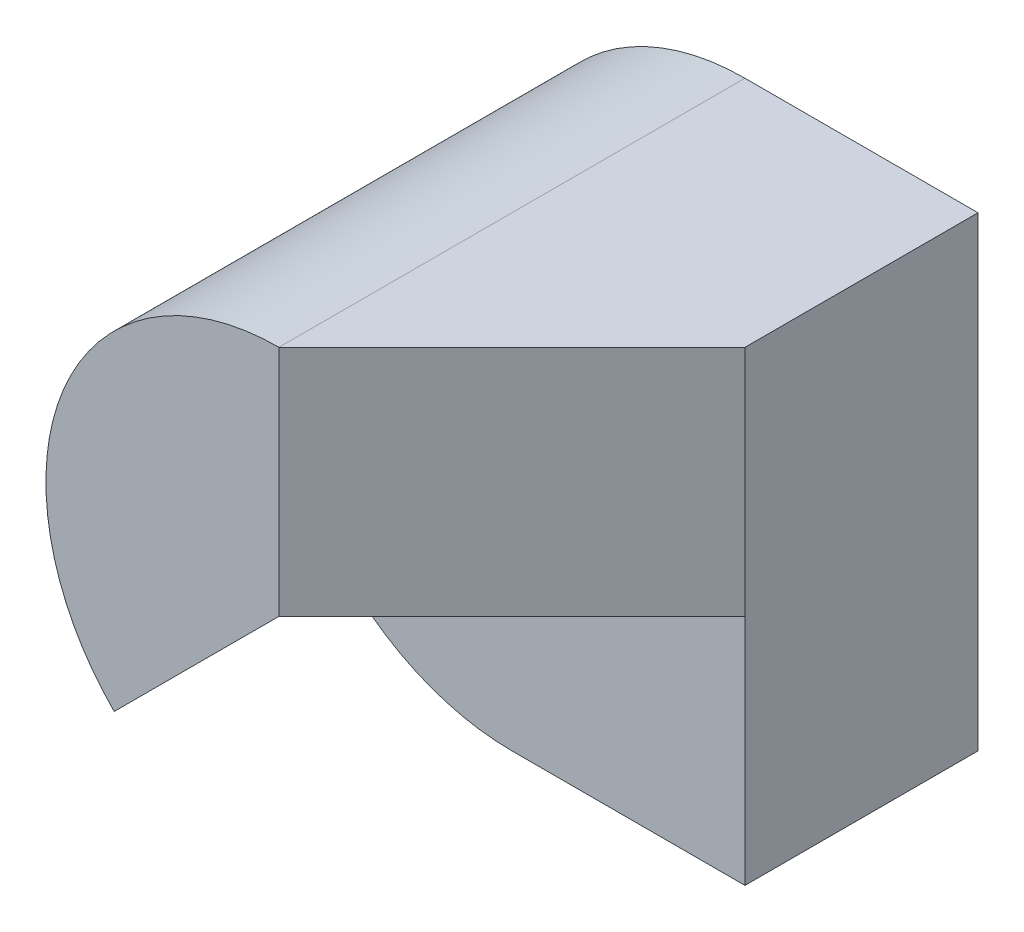
from build123d import *

# Parameters (mm, degrees)
BOSS_EXTRUDE1_DEPTH = 4
CUT_EXTRUDE2_DEPTH  = 2
CUT_EXTRUDE5_DEPTH  = 2


with BuildPart() as part:
    # Sketch1 → Boss-Extrude1 (new body)
    with BuildSketch(Plane.XY):
        with BuildLine():
            Line((0, 2), (2, 2))
            Line((2, 2), (2, -2))
            Line((2, -2), (0, -2))
            ThreePointArc((0, -2), (-2, 0), (0, 2))
        make_face()
    extrude(amount=BOSS_EXTRUDE1_DEPTH)

    # Sketch3 → Cut-Extrude2 (cut)
    with BuildSketch(Plane.XY.offset(4)):
        Polygon((2, 0), (0, 0), (-2, -2), (2, -2), align=None)
    extrude(amount=-CUT_EXTRUDE2_DEPTH, mode=Mode.SUBTRACT)

    # 3DSketch2 → Cut-Extrude5 (cut, along a direction that is not the sketch's normal)
    with BuildSketch(Plane(origin=(0, 0, 4), x_dir=(0.5773502691896283, 0.5773502691896234, -0.5773502691896257), z_dir=(-0.707106781186546, 0, -0.7071067811865491))):
        Polygon((0, 0), (2.309401077, 1.632993162), (3.464101615, 0), (1.154700538, -1.632993162), align=None)
    extrude(amount=-CUT_EXTRUDE5_DEPTH, dir=(0, 0, -1), mode=Mode.SUBTRACT)


solid = part.part
